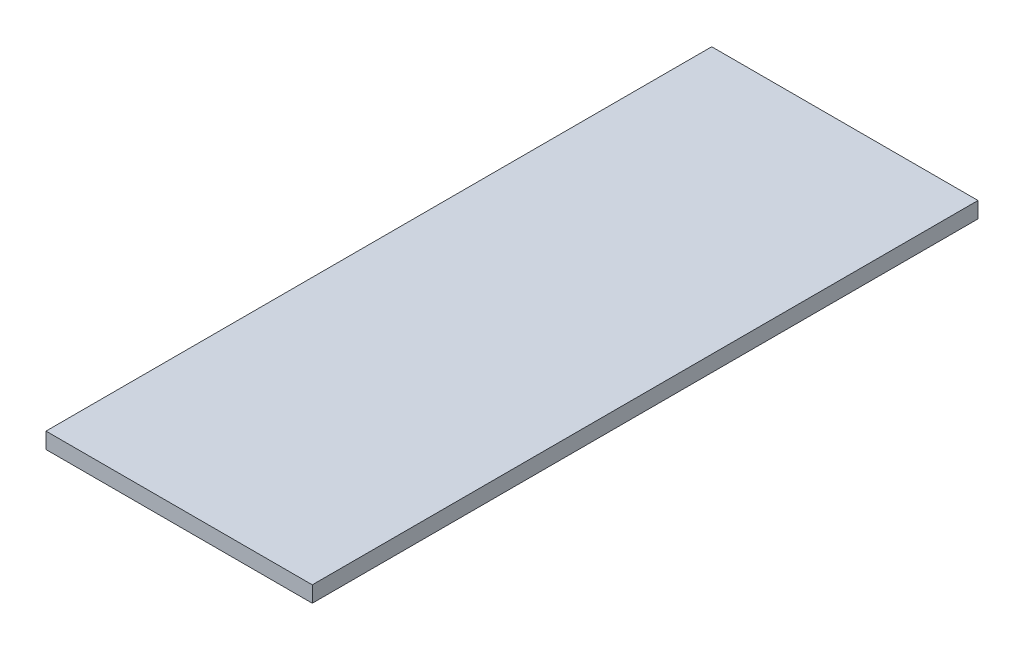
from build123d import *

# Parameters (mm, degrees)
SKETCH1_W           = 50
SKETCH1_H           = 125
BOSS_EXTRUDE1_DEPTH = 3


with BuildPart() as part:
    # Sketch1 → Boss-Extrude1 (new body)
    with BuildSketch(Plane(origin=(0, 0, 0), x_dir=(1, 0, 0), z_dir=(0, 1, 0))):
        Rectangle(SKETCH1_W, SKETCH1_H)
    extrude(amount=BOSS_EXTRUDE1_DEPTH)


solid = part.part
